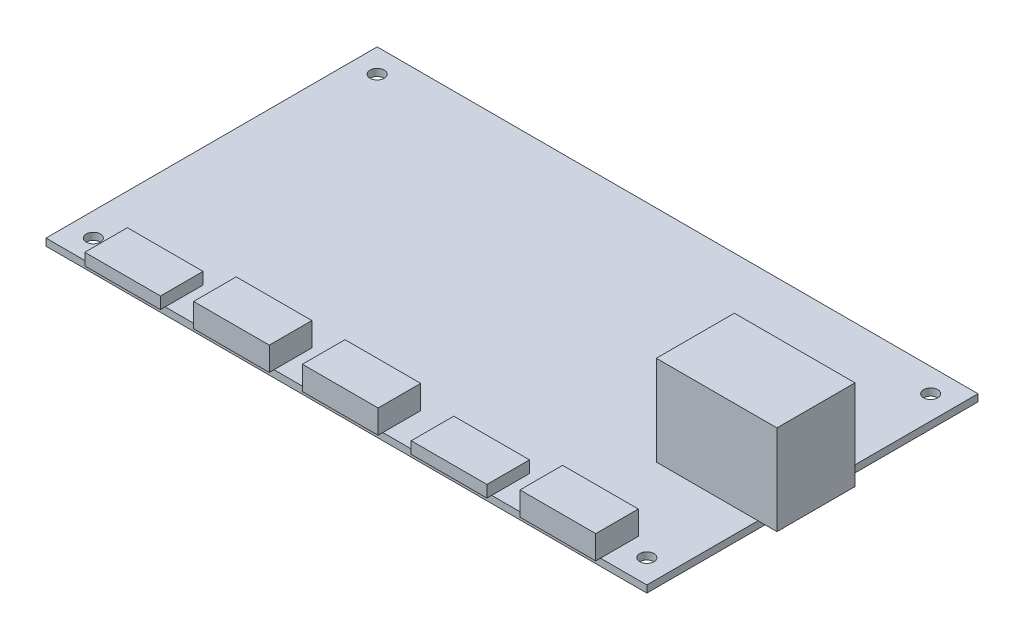
from build123d import *

# Parameters (mm, degrees)
ESQUISSE1_W        = 127
ESQUISSE1_H        = 70
ESQUISSE1_R        = 1.5
BOSS_EXTRU_1_DEPTH = 1.5
ESQUISSE2_W        = 16
ESQUISSE2_H        = 9
BOSS_EXTRU_2_DEPTH = 2.5
ESQUISSE2_3_W      = 16
ESQUISSE2_3_H      = 9
BOSS_EXTRU_3_DEPTH = 5
ESQUISSE2_4_W      = 25.5
ESQUISSE2_4_H      = 16.5
BOSS_EXTRU_4_DEPTH = 19


with BuildPart() as part:
    # Esquisse1 → Boss.-Extru.1 (new body)
    with BuildSketch(Plane(origin=(0, 0, 0), x_dir=(1, 0, 0), z_dir=(0, 1, 0))):
        Rectangle(ESQUISSE1_W, ESQUISSE1_H)
        with Locations((-58.5, 30)):
            Circle(ESQUISSE1_R, mode=Mode.SUBTRACT)
        with Locations((-58.5, -30)):
            Circle(ESQUISSE1_R, mode=Mode.SUBTRACT)
        with Locations((58.5, 30)):
            Circle(ESQUISSE1_R, mode=Mode.SUBTRACT)
        with Locations((58.5, -30)):
            Circle(ESQUISSE1_R, mode=Mode.SUBTRACT)
    extrude(amount=BOSS_EXTRU_1_DEPTH)

    # Esquisse2 → Boss.-Extru.2 (add)
    with BuildSketch(Plane(origin=(0, 1.5, 0), x_dir=(1, 0, 0), z_dir=(0, 1, 0))):
        with Locations((22.7, -31.5)):
            Rectangle(ESQUISSE2_W, ESQUISSE2_H)
        with Locations((-46.3, -31.5)):
            Rectangle(ESQUISSE2_W, ESQUISSE2_H)
    extrude(amount=BOSS_EXTRU_2_DEPTH)

    # Esquisse2_3 → Boss.-Extru.3 (add)
    with BuildSketch(Plane(origin=(0, 1.5, 0), x_dir=(1, 0, 0), z_dir=(0, 1, 0))):
        with Locations((-23.3, -31.5)):
            Rectangle(ESQUISSE2_3_W, ESQUISSE2_3_H)
        with Locations((45.7, -31.5)):
            Rectangle(ESQUISSE2_3_W, ESQUISSE2_3_H)
        with Locations((-0.3, -31.5)):
            Rectangle(ESQUISSE2_3_W, ESQUISSE2_3_H)
    extrude(amount=BOSS_EXTRU_3_DEPTH)

    # Esquisse2_4 → Boss.-Extru.4 (add)
    with BuildSketch(Plane(origin=(0, 1.5, 0), x_dir=(1, 0, 0), z_dir=(0, 1, 0))):
        with Locations((54.75, -3.25)):
            Rectangle(ESQUISSE2_4_W, ESQUISSE2_4_H)
    extrude(amount=BOSS_EXTRU_4_DEPTH)


solid = part.part
